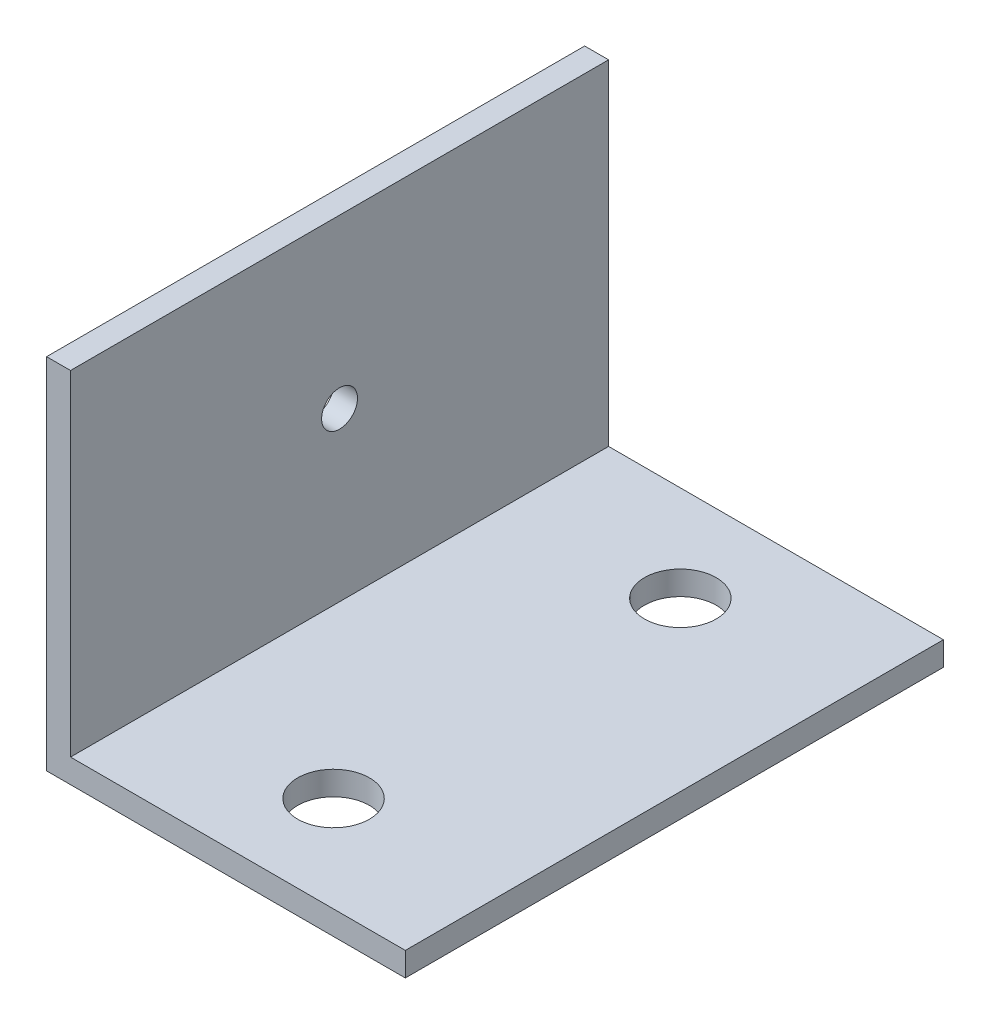
from build123d import *

# Parameters (mm, degrees)
P_IDAT_VYSUNUT_M1_DEPTH       = 45
D_RY_PRO_KOL_K_VELIKOST_MM1_D = 6
D_RY_PRO_KOL_K_VELIKOST_MM2_D = 3


with BuildPart() as part:
    # Skica1 → Přidat vysunutím1 (new body)
    with BuildSketch(Plane.XY):
        Polygon((-63.470895832, 45.782217357), (-63.470895832, 15.782217357), (-33.470895832, 15.782217357), (-33.470895832, 17.782217357), (-61.470895832, 17.782217357), (-61.470895832, 45.782217357), align=None)
    extrude(amount=P_IDAT_VYSUNUT_M1_DEPTH)

    # Díry pro kolík, velikost mm1 (through all)
    with Locations(Plane(origin=(0, 17.782217357, 0), x_dir=(1, 0, 0), z_dir=(0, 1, 0))):
        with Locations((-47.470895832, -37), (-47.470895832, -8)):
            Hole(D_RY_PRO_KOL_K_VELIKOST_MM1_D / 2)

    # Díry pro kolík, velikost mm2 (through all)
    with Locations(Plane(origin=(-61.470895832, 0, 0), x_dir=(0, 0, -1), z_dir=(1, 0, 0))):
        with Locations((-22.5, 31.782217357)):
            Hole(D_RY_PRO_KOL_K_VELIKOST_MM2_D / 2)


solid = part.part
